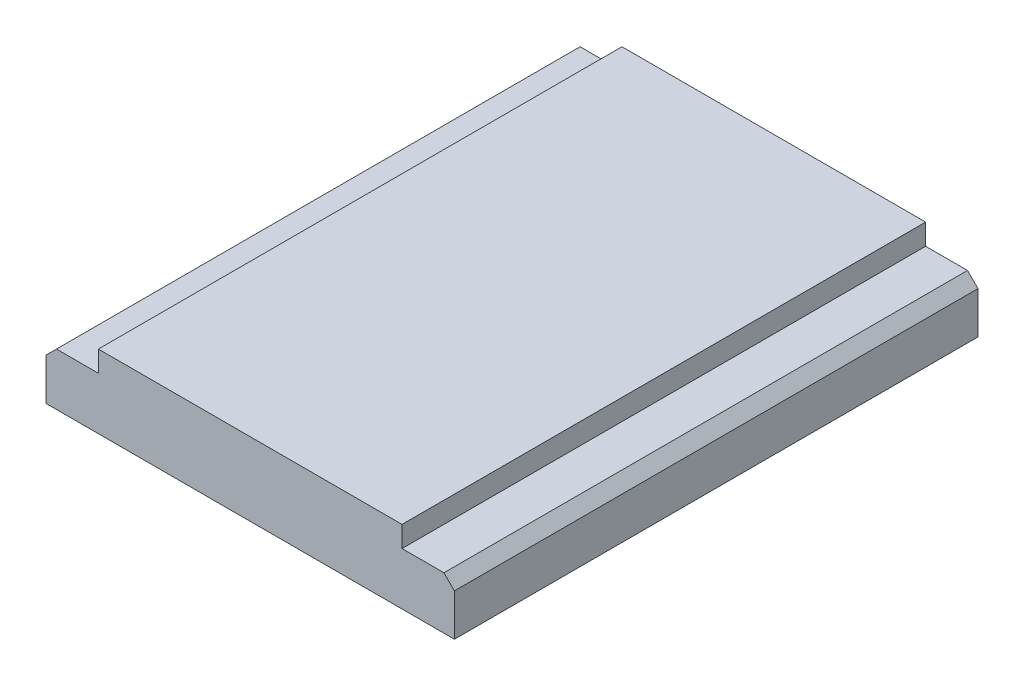
from build123d import *

# Parameters (mm, degrees)
BOSS_EXTRUDE1_DEPTH = 10
CHAMFER1_SIZE       = 0.2


with BuildPart() as part:
    # Sketch1 → Boss-Extrude1 (new body)
    with BuildSketch(Plane.XY):
        Polygon((0, 0), (7.8, 0), (7.8, 1), (6.8, 1), (6.8, 1.4), (1, 1.4), (1, 1), (0, 1), align=None)
    extrude(amount=BOSS_EXTRUDE1_DEPTH)

    # Chamfer1
    chamfer1_edges = [part.edges().sort_by_distance(p)[0] for p in [
        (0, 1, 5),
        (7.8, 1, 5),
    ]]
    chamfer(chamfer1_edges, length=CHAMFER1_SIZE)


solid = part.part
